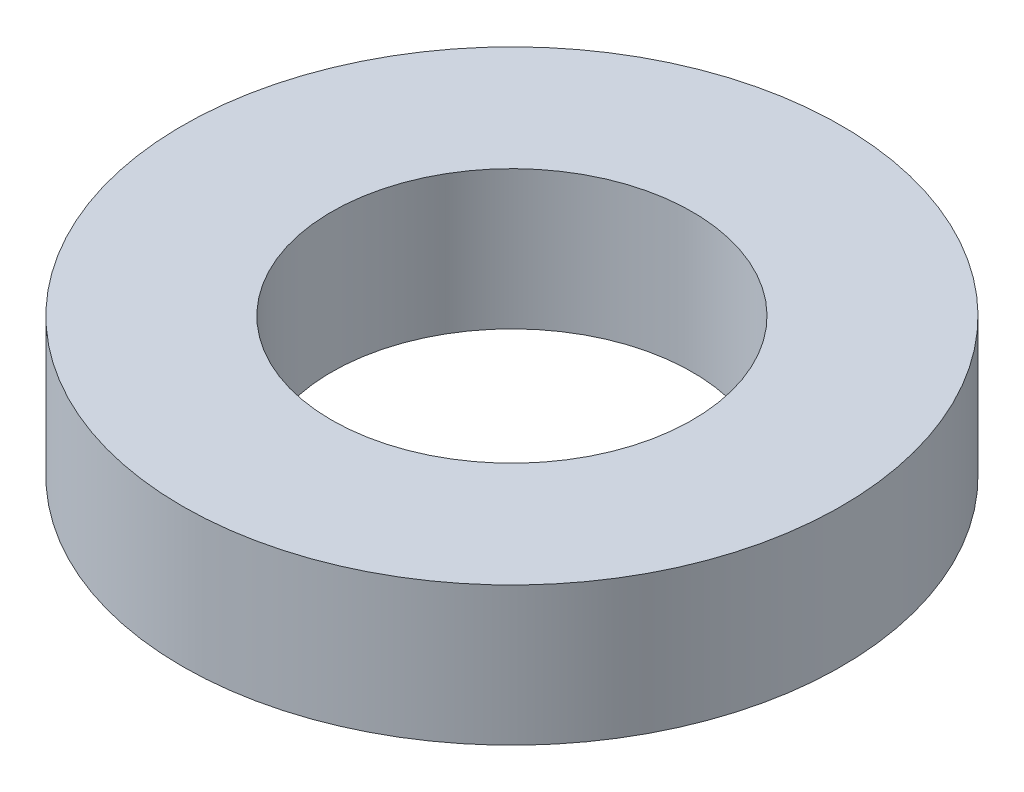
from build123d import *

# Parameters (mm, degrees)
SKETCH1_R           = 4.75
SKETCH1_R_2         = 2.6
BOSS_EXTRUDE1_DEPTH = 2


with BuildPart() as part:
    # Sketch1 → Boss-Extrude1 (new body)
    with BuildSketch(Plane(origin=(0, 0, 0), x_dir=(1, 0, 0), z_dir=(0, 1, 0))):
        Circle(SKETCH1_R)
        Circle(SKETCH1_R_2, mode=Mode.SUBTRACT)
    extrude(amount=BOSS_EXTRUDE1_DEPTH)


solid = part.part
